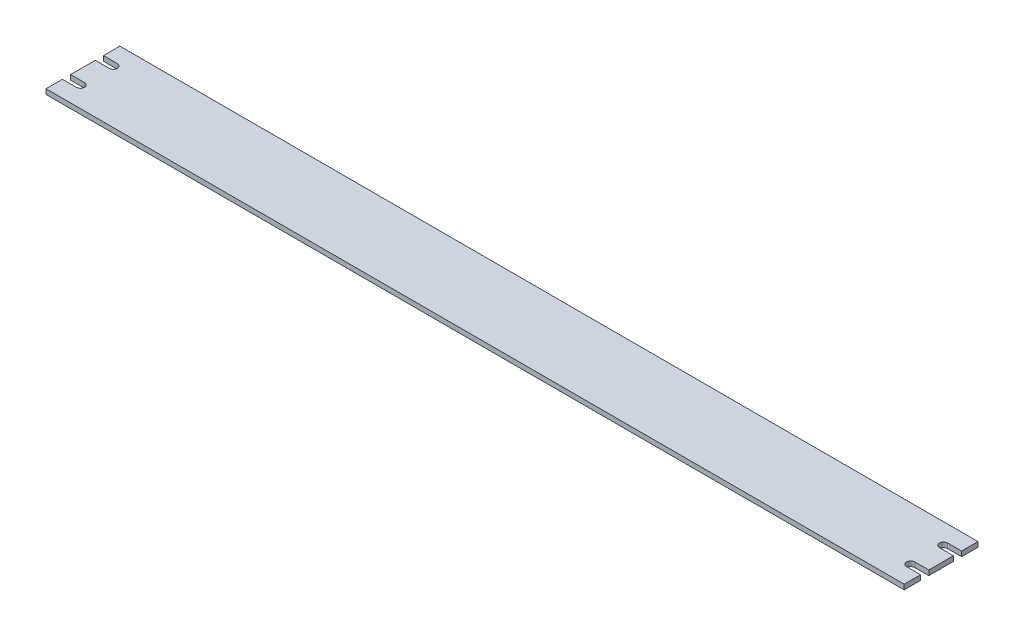
from build123d import *

# Parameters (mm, degrees)
SKETCH2_W           = 523
SKETCH2_H           = 45
BOSS_EXTRUDE1_DEPTH = 3
CUT_EXTRUDE1_DEPTH  = 4


with BuildPart() as part:
    # Sketch2 → Boss-Extrude1 (new body)
    with BuildSketch(Plane(origin=(0, 0, 0), x_dir=(1, 0, 0), z_dir=(0, 1, 0))):
        Rectangle(SKETCH2_W, SKETCH2_H)
    extrude(amount=BOSS_EXTRUDE1_DEPTH)

    # Sketch3 → Cut-Extrude1 (cut, through all)
    with BuildSketch(Plane(origin=(0, 3, 0), x_dir=(1, 0, 0), z_dir=(0, 1, 0))):
        with BuildLine():
            Line((-261.5, 12.5), (-253, 12.5))
            ThreePointArc((-253, 12.5), (-250.5, 10), (-253, 7.5))
            Line((-253, 7.5), (-261.5, 7.5))
            ThreePointArc((-261.5, 7.5), (-264, 10), (-261.5, 12.5))
        make_face()
        with BuildLine():
            Line((-261.5, -12.5), (-253, -12.5))
            ThreePointArc((-253, -12.5), (-250.5, -10), (-253, -7.5))
            Line((-253, -7.5), (-261.5, -7.5))
            ThreePointArc((-261.5, -7.5), (-264, -10), (-261.5, -12.5))
        make_face()
        with BuildLine():
            Line((261.5, 12.5), (253, 12.5))
            ThreePointArc((253, 12.5), (250.5, 10), (253, 7.5))
            Line((253, 7.5), (261.5, 7.5))
            ThreePointArc((261.5, 7.5), (264, 10), (261.5, 12.5))
        make_face()
        with BuildLine():
            Line((261.5, -12.5), (253, -12.5))
            ThreePointArc((253, -12.5), (250.5, -10), (253, -7.5))
            Line((253, -7.5), (261.5, -7.5))
            ThreePointArc((261.5, -7.5), (264, -10), (261.5, -12.5))
        make_face()
    extrude(amount=-CUT_EXTRUDE1_DEPTH, mode=Mode.SUBTRACT)


solid = part.part
